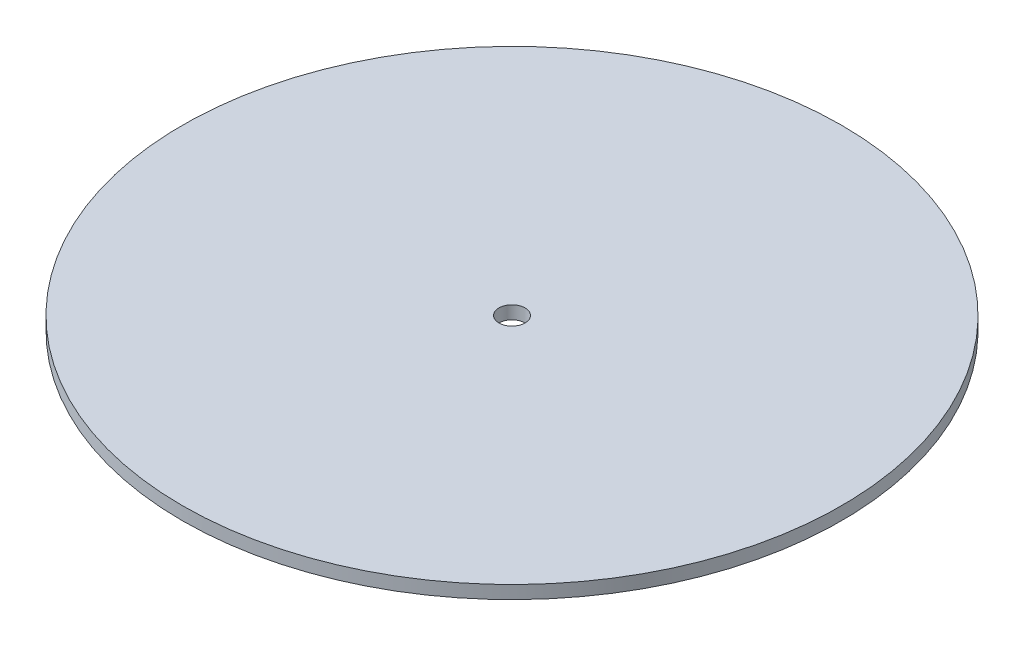
from build123d import *

# Parameters (mm, degrees)
SKETCH3_R           = 126
BOSS_EXTRUDE1_DEPTH = 5
SKETCH4_R           = 5
CUT_EXTRUDE1_DEPTH  = 5


with BuildPart() as part:
    # Sketch3 → Boss-Extrude1 (new body)
    with BuildSketch(Plane(origin=(0, 0, 0), x_dir=(1, 0, 0), z_dir=(0, 1, 0))):
        Circle(SKETCH3_R)
    extrude(amount=BOSS_EXTRUDE1_DEPTH)

    # Sketch4 → Cut-Extrude1 (cut)
    with BuildSketch(Plane(origin=(0, 5, 0), x_dir=(1, 0, 0), z_dir=(0, 1, 0))):
        Circle(SKETCH4_R)
    extrude(amount=-CUT_EXTRUDE1_DEPTH, mode=Mode.SUBTRACT)


solid = part.part
